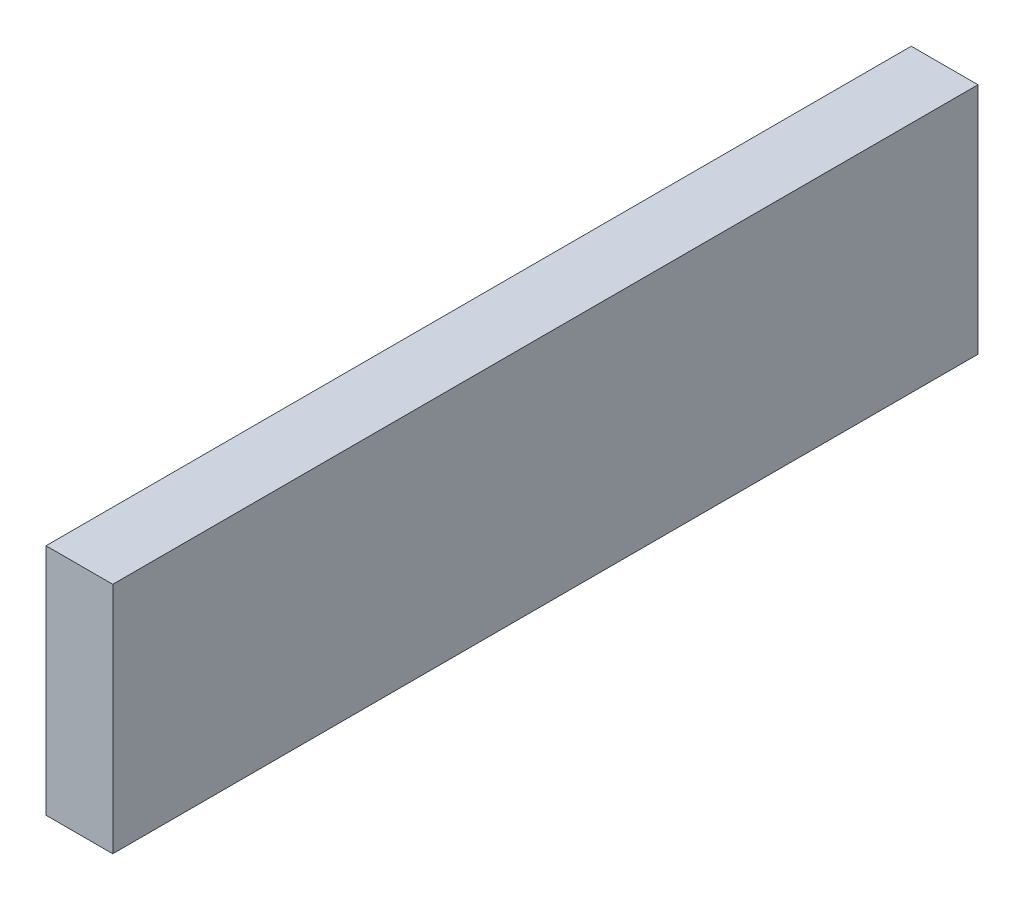
from build123d import *

# Parameters (mm, degrees)
BOSS_EXTRUDE1_DEPTH = 1.25
SKETCH2_W           = 16.2
SKETCH2_H           = 13.83
CUT_EXTRUDE1_DEPTH  = 1.25
SKETCH3_W           = 1.25
SKETCH3_H           = 16.2
BOSS_EXTRUDE2_DEPTH = 0.4


with BuildPart() as part:
    # Sketch1 → Boss-Extrude1 (new body)
    with BuildSketch(Plane(origin=(0, 0, 0), x_dir=(0, 0, -1), z_dir=(1, 0, 0))):
        Polygon((0, 0), (16.2, 0), (16.2, 17.8), (15.6, 17.8), (15.6, 3.97), (0.6, 3.97), (0.6, 17.8), (0, 17.8), align=None)
    extrude(amount=BOSS_EXTRUDE1_DEPTH)

    # Sketch2 → Cut-Extrude1 (cut)
    with BuildSketch(Plane(origin=(1.25, 0, 0), x_dir=(0, 0, -1), z_dir=(1, 0, 0))):
        with Locations((8.1, 10.885)):
            Rectangle(SKETCH2_W, SKETCH2_H)
    extrude(amount=-CUT_EXTRUDE1_DEPTH, mode=Mode.SUBTRACT)

    # Sketch3 → Boss-Extrude2 (add)
    with BuildSketch(Plane(origin=(0, 3.97, 0), x_dir=(1, 0, 0), z_dir=(0, 1, 0))):
        with Locations((0.625, 8.1)):
            Rectangle(SKETCH3_W, SKETCH3_H)
    extrude(amount=BOSS_EXTRUDE2_DEPTH)


solid = part.part
